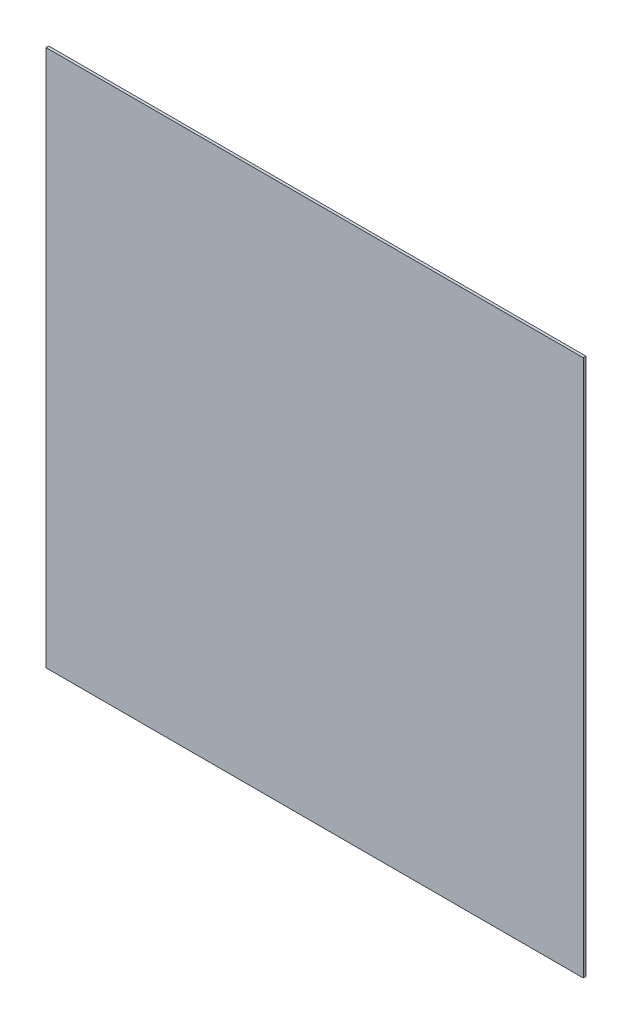
from build123d import *

# Parameters (mm, degrees)
ESQUISSE1_W        = 600
ESQUISSE1_H        = 600
BOSS_EXTRU_1_DEPTH = 3


with BuildPart() as part:
    # Esquisse1 → Boss.-Extru.1 (new body)
    with BuildSketch(Plane.XY):
        with Locations((-300, 300)):
            Rectangle(ESQUISSE1_W, ESQUISSE1_H)
    extrude(amount=BOSS_EXTRU_1_DEPTH)


solid = part.part
